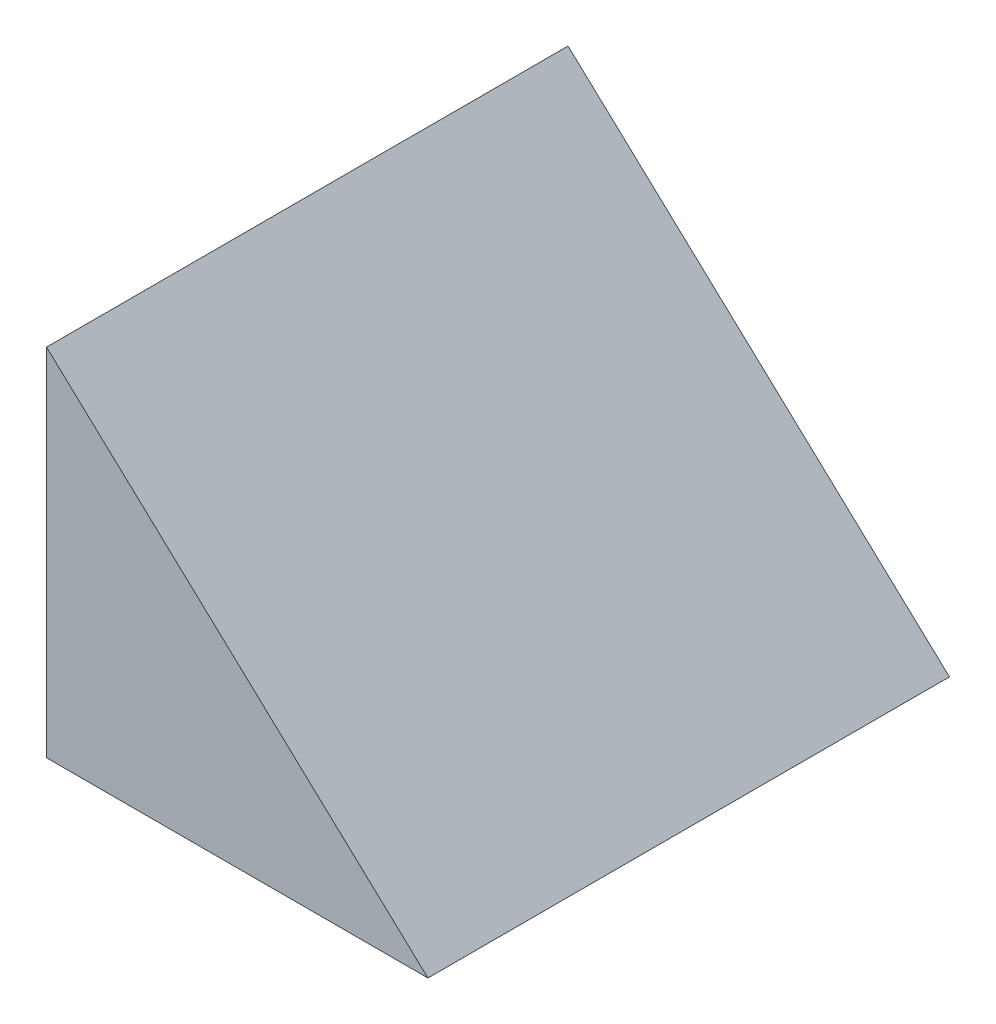
from build123d import *

# Parameters (mm, degrees)
BOSS_EXTRUDE1_DEPTH = 30
SKETCH3_R           = 1.5
CUT_EXTRUDE1_DEPTH  = 7.5
SKETCH6_W           = 27
SKETCH6_H           = 13.5
CUT_EXTRUDE2_DEPTH  = 6


with BuildPart() as part:
    # Sketch1 → Boss-Extrude1 (new body)
    with BuildSketch(Plane.XY):
        Polygon((0, 0), (21.940611049, 0), (0, 20.459950802), align=None)
    extrude(amount=-BOSS_EXTRUDE1_DEPTH)

    # Sketch3 → Cut-Extrude1 (cut)
    with BuildSketch(Plane.XZ):
        with Locations((11.940611049, -15)):
            Circle(SKETCH3_R)
    extrude(amount=-CUT_EXTRUDE1_DEPTH, mode=Mode.SUBTRACT)

    # Sketch6 → Cut-Extrude2 (cut)
    with BuildSketch(Plane.ZY):
        with Locations((-15, 6.75)):
            Rectangle(SKETCH6_W, SKETCH6_H)
    extrude(amount=-CUT_EXTRUDE2_DEPTH, mode=Mode.SUBTRACT)


solid = part.part
